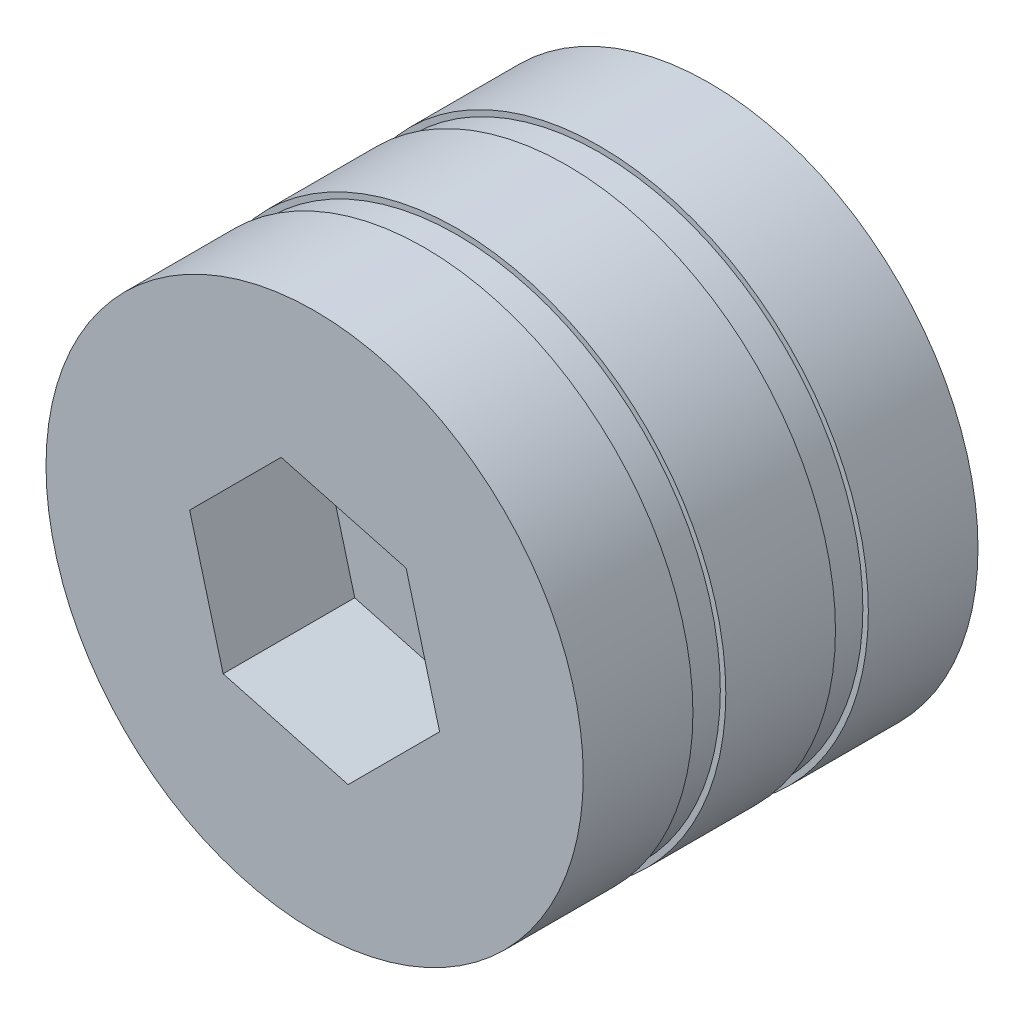
from build123d import *

# Parameters (mm, degrees)
SKETCH1_R           = 24.5
BOSS_EXTRUDE1_DEPTH = 36
CUT_EXTRUDE1_DEPTH  = 12
CUT_EXTRUDE2_START  = -10
SKETCH3_R           = 24.5
SKETCH3_R_2         = 24
CUT_EXTRUDE2_DEPTH  = 3
CUT_EXTRUDE3_START  = -23
SKETCH4_R           = 24.5
SKETCH4_R_2         = 24
CUT_EXTRUDE3_DEPTH  = 3


with BuildPart() as part:
    # Sketch1 → Boss-Extrude1 (new body)
    with BuildSketch(Plane.XY):
        Circle(SKETCH1_R)
    extrude(amount=BOSS_EXTRUDE1_DEPTH)

    # Sketch2 → Cut-Extrude1 (cut)
    with BuildSketch(Plane.XY.offset(36)):
        Polygon((8.343860018, 8.343860018), (-3.054064732, 11.39792475), (-11.39792475, 3.054064732), (-8.343860018, -8.343860018), (3.054064732, -11.39792475), (11.39792475, -3.054064732), align=None)
    extrude(amount=-CUT_EXTRUDE1_DEPTH, mode=Mode.SUBTRACT)

    # Sketch3 → Cut-Extrude2 (cut)
    with BuildSketch(Plane.XY.offset(36).offset(CUT_EXTRUDE2_START)):
        Circle(SKETCH3_R)
        Circle(SKETCH3_R_2, mode=Mode.SUBTRACT)
    extrude(amount=-CUT_EXTRUDE2_DEPTH, mode=Mode.SUBTRACT)

    # Sketch4 → Cut-Extrude3 (cut)
    with BuildSketch(Plane.XY.offset(36).offset(CUT_EXTRUDE3_START)):
        Circle(SKETCH4_R)
        Circle(SKETCH4_R_2, mode=Mode.SUBTRACT)
    extrude(amount=-CUT_EXTRUDE3_DEPTH, mode=Mode.SUBTRACT)


solid = part.part
